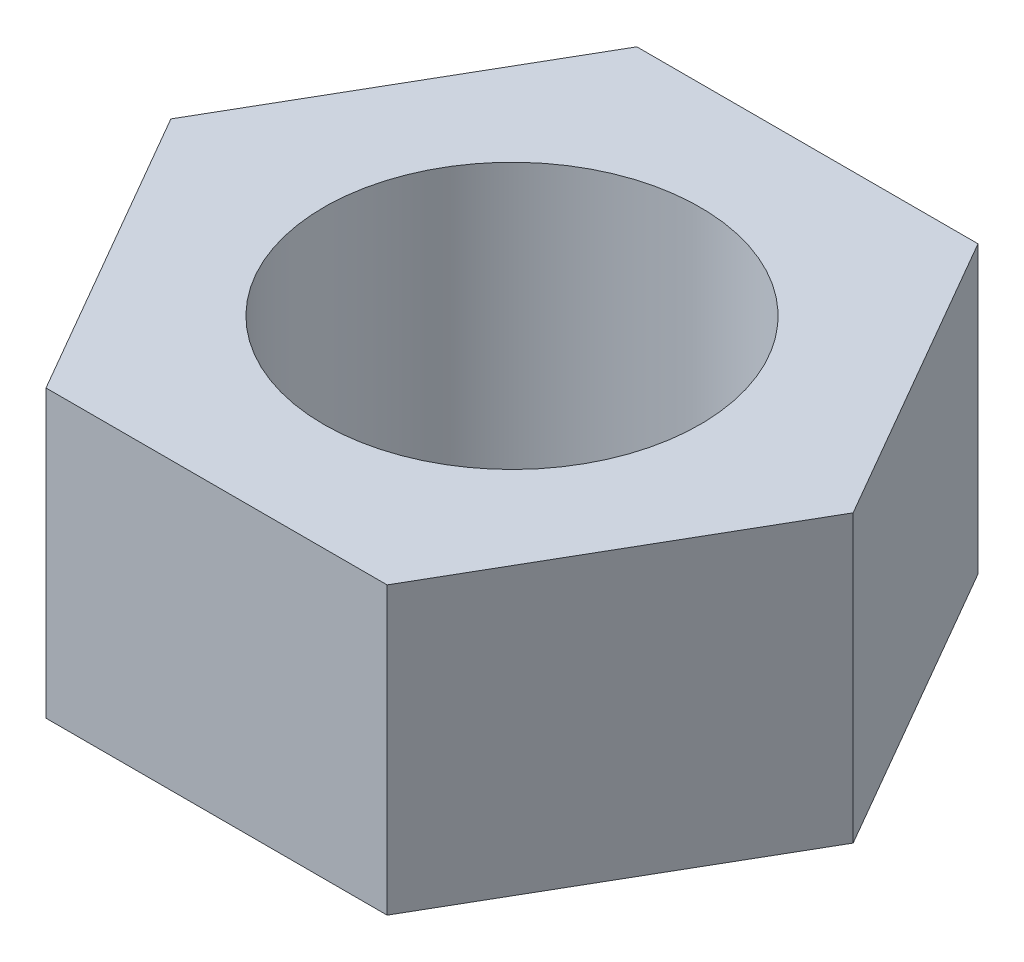
from build123d import *

# Parameters (mm, degrees)
SKETCH_1_R      = 2.5
EXTRUDE_1_DEPTH = 3.8


with BuildPart() as part:
    # 草图1 → 凸台-拉伸1 (new body)
    with BuildSketch(Plane(origin=(0, 0, 0), x_dir=(1, 0, 0), z_dir=(0, 1, 0))):
        Polygon((4.532199613, 0), (2.266099807, 3.925), (-2.266099807, 3.925), (-4.532199613, 0), (-2.266099807, -3.925), (2.266099807, -3.925), align=None)
        Circle(SKETCH_1_R, mode=Mode.SUBTRACT)
    extrude(amount=EXTRUDE_1_DEPTH)


solid = part.part
